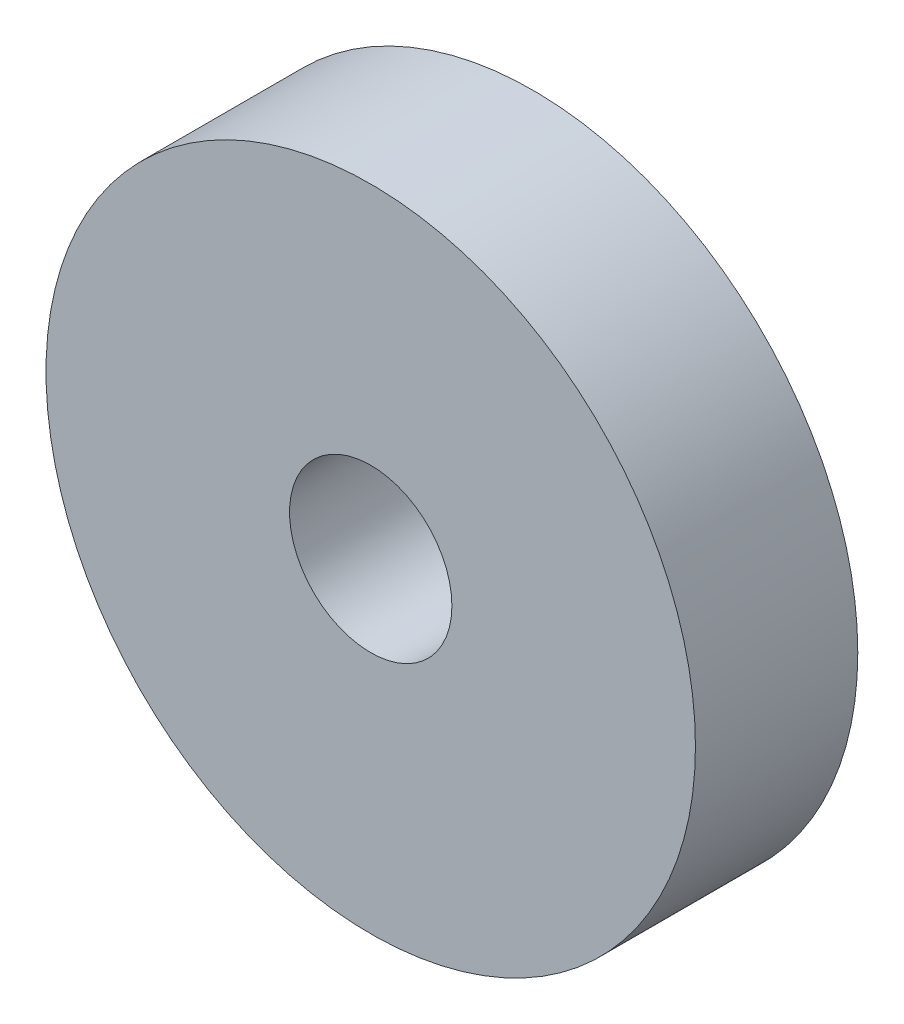
from build123d import *

# Parameters (mm, degrees)
SKETCH1_R           = 10
SKETCH1_R_2         = 2.5
BOSS_EXTRUDE1_DEPTH = 5


with BuildPart() as part:
    # Sketch1 → Boss-Extrude1 (new body)
    with BuildSketch(Plane.XY):
        Circle(SKETCH1_R)
        Circle(SKETCH1_R_2, mode=Mode.SUBTRACT)
    extrude(amount=BOSS_EXTRUDE1_DEPTH)


solid = part.part
